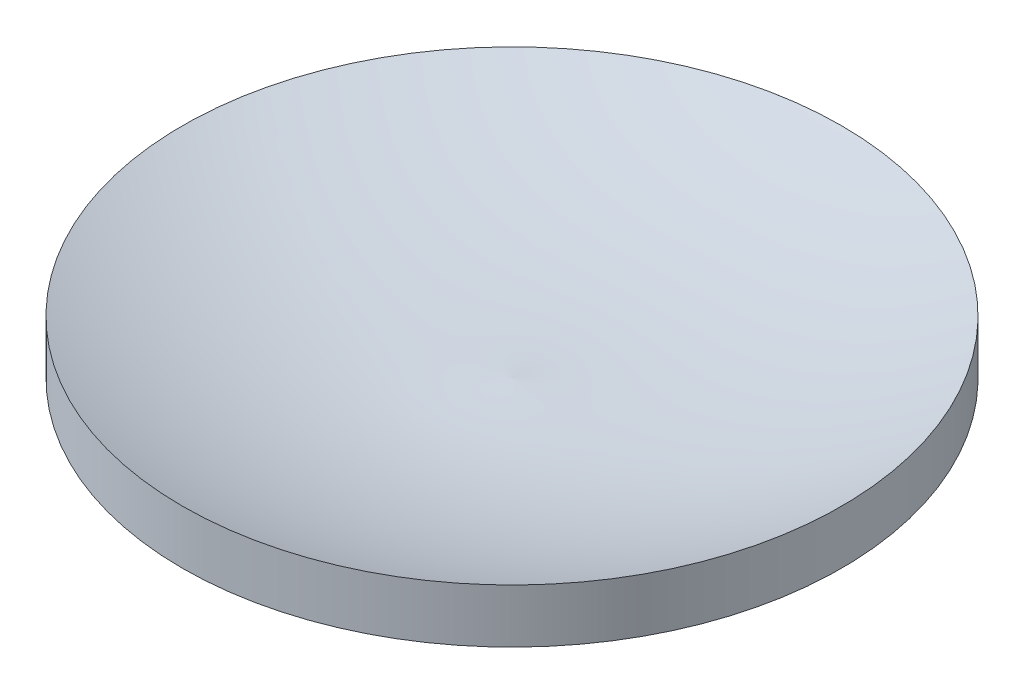
from build123d import *


with BuildPart() as part:
    # Sketch1 → Revolve1 (revolve)
    with BuildSketch(Plane(origin=(0, 0, 0), x_dir=(0, 0, -1), z_dir=(1, 0, 0))):
        with BuildLine():
            Line((49, 8), (49, 16))
            ThreePointArc((49, 16), (24.973839769, 9.097731414), (0, 8))
            Line((0, 8), (0, 0))
            ThreePointArc((0, 0), (24.824383175, 2.013153055), (49, 8))
        make_face()
    revolve(axis=Axis((0, 0, 0), (0, 1, 0)))


solid = part.part
